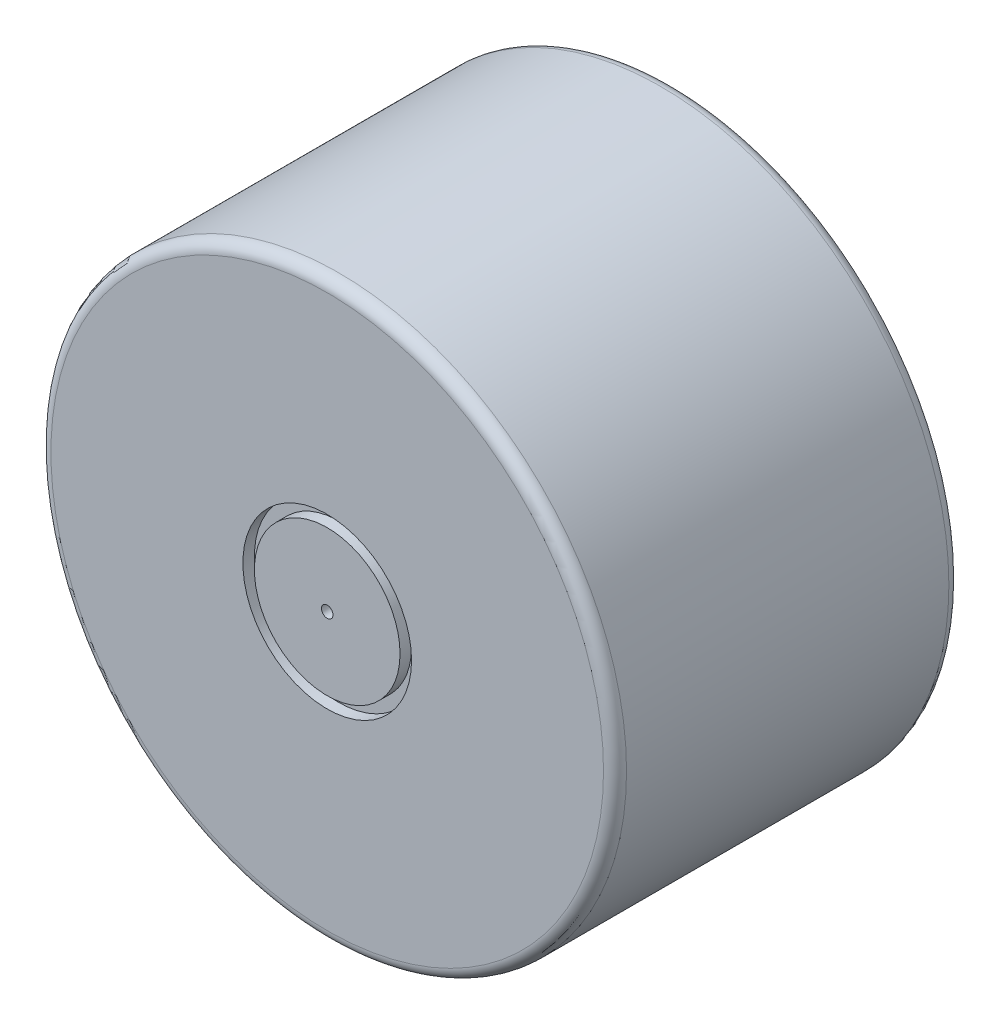
from build123d import *

# Parameters (mm, degrees)
SKETCH1_R          = 250
EXTRUDE1_DEPTH     = 300
SKETCH2_R          = 5
CUT_EXTRUDE1_DEPTH = 20
SKETCH3_R          = 200
SKETCH3_R_2        = 89.818842926
CUT_EXTRUDE2_DEPTH = 100
SKETCH4_R          = 89.818842926
CUT_EXTRUDE3_DEPTH = 20
FILLET1_R          = 10
SKETCH6_R          = 73.258337553
SKETCH6_R_2        = 63.258337553
CUT_EXTRUDE4_DEPTH = 10


with BuildPart() as part:
    # Sketch1 → Extrude1 (new body)
    with BuildSketch(Plane.XY):
        Circle(SKETCH1_R)
    extrude(amount=EXTRUDE1_DEPTH)

    # Sketch2 → Cut-Extrude1 (cut)
    with BuildSketch(Plane.XY.offset(300)):
        Circle(SKETCH2_R)
    extrude(amount=-CUT_EXTRUDE1_DEPTH, mode=Mode.SUBTRACT)

    # Sketch3 → Cut-Extrude2 (cut)
    with BuildSketch(Plane(origin=(0, 0, 0), x_dir=(-1, 0, 0), z_dir=(0, 0, -1))):
        Circle(SKETCH3_R)
        Circle(SKETCH3_R_2, mode=Mode.SUBTRACT)
    extrude(amount=-CUT_EXTRUDE2_DEPTH, mode=Mode.SUBTRACT)

    # Sketch4 → Cut-Extrude3 (cut)
    with BuildSketch(Plane(origin=(0, 0, 0), x_dir=(-1, 0, 0), z_dir=(0, 0, -1))):
        Circle(SKETCH4_R)
    extrude(amount=-CUT_EXTRUDE3_DEPTH, mode=Mode.SUBTRACT)

    # Sketch5 → Revolve1 (revolve)
    with BuildSketch(Plane(origin=(0, 0, 0), x_dir=(1, 0, 0), z_dir=(0, 1, 0))):
        with BuildLine():
            Line((0, -20), (0, 0))
            ThreePointArc((0, 0), (-46.360181472, -3.484720731), (-89.818842926, -20))
            Line((-89.818842926, -20), (0, -20))
        make_face()
    revolve(axis=Axis((0, 0, 20), (0, 0, -1)))

    # Fillet1
    fillet1_edges = [part.edges().sort_by_distance(p)[0] for p in [
        (-250, 0, 0),
        (-250, 0, 300),
    ]]
    fillet(fillet1_edges, radius=FILLET1_R)

    # Sketch6 → Cut-Extrude4 (cut)
    with BuildSketch(Plane.XY.offset(300)):
        Circle(SKETCH6_R)
        Circle(SKETCH6_R_2, mode=Mode.SUBTRACT)
    extrude(amount=-CUT_EXTRUDE4_DEPTH, mode=Mode.SUBTRACT)


solid = part.part
